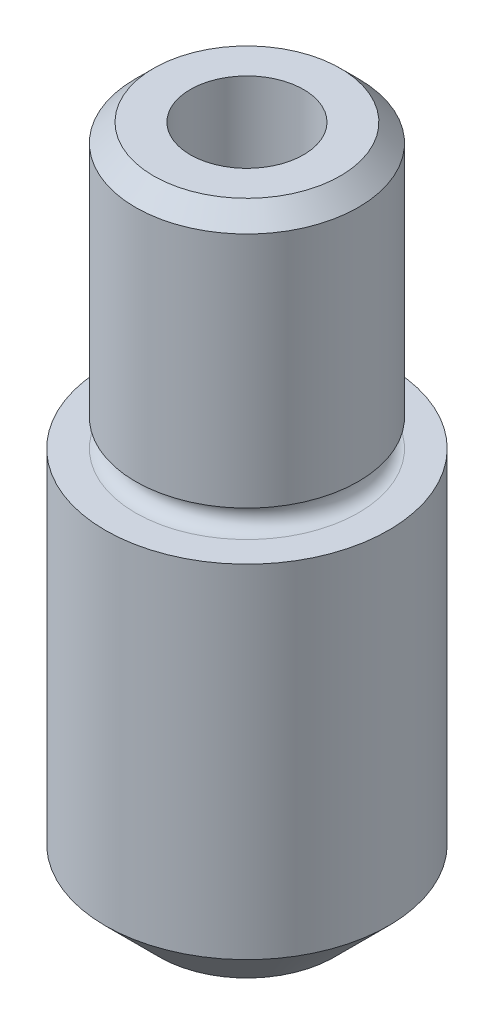
from build123d import *

# Parameters (mm, degrees)
SKETCH1_R                      = 1.98501
BASE_EXTRUDE_DEPTH             = 9.525
SKETCH2_R                      = 1.98501
SKETCH2_R_2                    = 1.5621
CUT_EXTRUDE2_DEPTH             = 3.9624
CHAMFER1_SIZE                  = 0.254
CHAMFER2_SIZE                  = 0.762
SKETCH4_R                      = 0.1905
F_1_16_0_0625_DIAMETER_HOLE1_D = 1.5875


with BuildPart() as part:
    # Sketch1 → Base-Extrude (new body)
    with BuildSketch(Plane(origin=(0, 0, 0), x_dir=(1, 0, 0), z_dir=(0, 1, 0))):
        with Locations(Location((0, 0, 0), (0, 0, 270))):  # turned: the seam where the file's is
            Circle(SKETCH1_R)
    extrude(amount=BASE_EXTRUDE_DEPTH)

    # Sketch2 → Cut-Extrude2 (cut)
    with BuildSketch(Plane(origin=(0, 9.525, 0), x_dir=(1, 0, 0), z_dir=(0, 1, 0))):
        with Locations(Location((0, 0, 0), (0, 0, 270))):  # turned: the seam where the file's is
            Circle(SKETCH2_R)
        with Locations(Location((0, 0, 0), (0, 0, 270))):  # turned: the seam where the file's is
            Circle(SKETCH2_R_2, mode=Mode.SUBTRACT)
    extrude(amount=-CUT_EXTRUDE2_DEPTH, mode=Mode.SUBTRACT)

    # Chamfer1
    chamfer1_edges = [part.edges().sort_by_distance(p)[0] for p in [
        (0, 9.525, -1.5621),
    ]]
    chamfer(chamfer1_edges, length=CHAMFER1_SIZE)

    # Chamfer2
    chamfer2_edges = [part.edges().sort_by_distance(p)[0] for p in [
        (0, 0, -1.98501),
    ]]
    chamfer(chamfer2_edges, length=CHAMFER2_SIZE)

    # Sketch4 → Cut-Revolve1 (revolve, cut)
    with BuildSketch(Plane.XY, mode=Mode.PRIVATE) as cut_revolve1_sk:
        with Locations((-1.5621, 5.7531)):
            Circle(SKETCH4_R)
    revolve(cut_revolve1_sk.sketch.rotate(Axis((0, 9.525, 0), (0, -1, 0)), 270), axis=Axis((0, 9.525, 0), (0, -1, 0)), mode=Mode.SUBTRACT)  # turned: the seam where the file's is

    # 1/16 (0.0625) Diameter Hole1 (through all)
    with Locations(Plane(origin=(0, 9.525, 0), x_dir=(-1, 0, 0), z_dir=(0, 1, 0))):
        with Locations((0, 0)):
            Hole(F_1_16_0_0625_DIAMETER_HOLE1_D / 2)


solid = part.part
